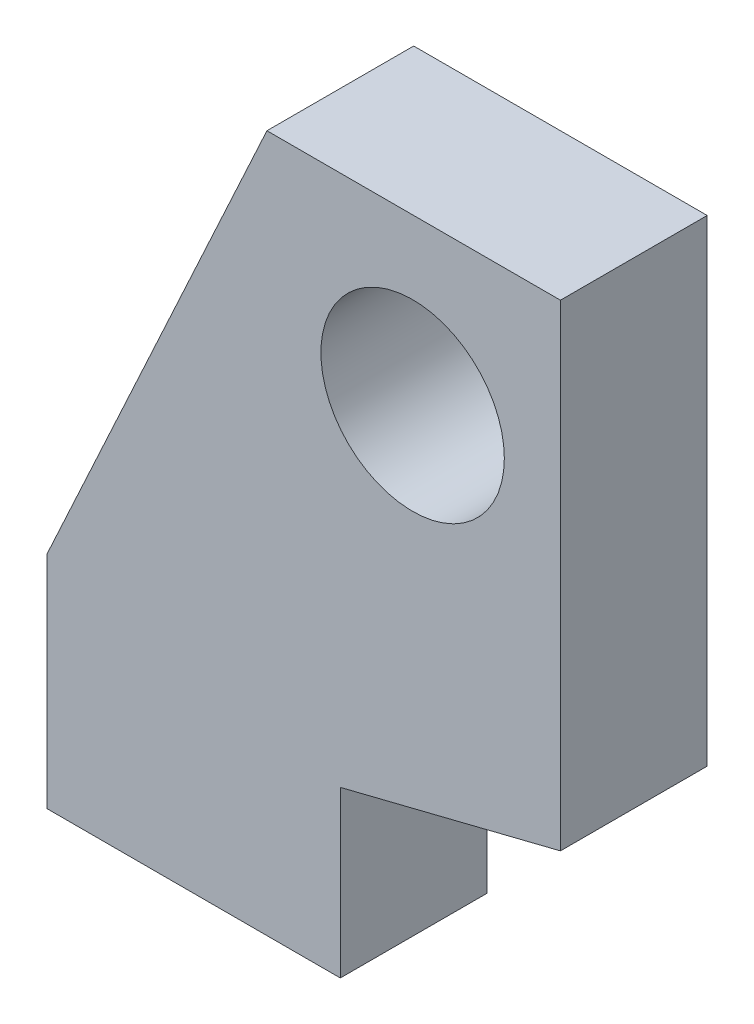
from build123d import *

# Parameters (mm, degrees)
SKETCH1_R           = 2.5
BOSS_EXTRUDE1_DEPTH = 4


with BuildPart() as part:
    # Sketch1 → Boss-Extrude1 (new body)
    with BuildSketch(Plane.XY):
        Polygon((-6, 0), (-6, -6), (2, -6), (2, -1.5), (8, 0), (8, 13), (0, 13), align=None)
        with Locations((3.970811984, 8.5)):
            Circle(SKETCH1_R, mode=Mode.SUBTRACT)
    extrude(amount=BOSS_EXTRUDE1_DEPTH)


solid = part.part
